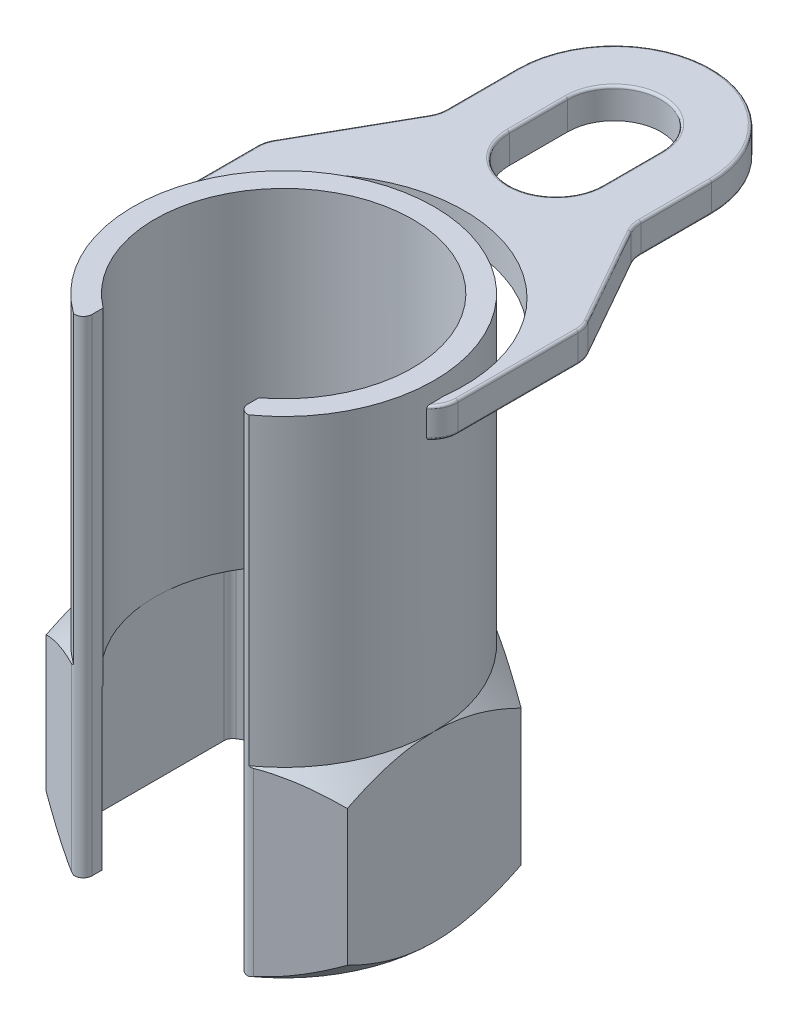
from build123d import *
from build123d.topology import SkipClean

# Parameters (mm, degrees)
EXTRUDE1_DEPTH     = 37.5
EXTRUDE2_DEPTH     = 62.5
SKETCH8_OUTSIDE_W  = 292.536
SKETCH8_OUTSIDE_H  = 292.878
SKETCH8_OUTSIDE_R  = 30.960408185
CUT_EXTRUDE4_DEPTH = 101
CUT_EXTRUDE4_DRAFT = -45
SKETCH19_OUTSIDE_W = 167.536
SKETCH19_OUTSIDE_H = 167.878
SKETCH19_OUTSIDE_R = 30.960308185
CUT_EXTRUDE6_DEPTH = 38.5
CUT_EXTRUDE6_DRAFT = -45
CUT_EXTRUDE9_START = -32.710308
CUT_EXTRUDE9_DEPTH = 32.710309
FILLET1_R          = 1.8
EXTRUDE7_DEPTH     = 6.2
CUT_EXTRUDE8_REACH = 98.2
FILLET4_R          = 0.5


with BuildPart() as part:
    # Sketch1 → Extrude1 (new body)
    with BuildSketch(Plane(origin=(0, 0, 0), x_dir=(1, 0, 0), z_dir=(0, 1, 0))):
        with BuildLine():
            Line((-16, -21.124630174), (-16, -26.512395693))
            Line((-16, -26.512395693), (-30.960408185, -17.875))
            Line((-30.960408185, -17.875), (-30.960408185, 17.875))
            Line((-30.960408185, 17.875), (0, 35.75))
            Line((0, 35.75), (30.960408185, 17.875))
            Line((30.960408185, 17.875), (30.960408185, -17.875))
            Line((30.960408185, -17.875), (16, -26.512395693))
            Line((16, -26.512395693), (16, -21.124630174))
            ThreePointArc((16, -21.124630174), (0, 26.5), (-16, -21.124630174))
        make_face()
    extrude(amount=EXTRUDE1_DEPTH)

    # Sketch3 → Extrude2 (add)
    with BuildSketch(Plane(origin=(0, 37.5, 0), x_dir=(-1, 0, 0), z_dir=(0, 1, 0))):
        with BuildLine():
            Line((-16, 26.505484016), (-16, 21.124630174))
            ThreePointArc((-16, 21.124630174), (0, -26.5), (16, 21.124630174))
            Line((16, 21.124630174), (16, 26.505484016))
            ThreePointArc((16, 26.505484016), (0, -30.960308185), (-16, 26.505484016))
        make_face()
    extrude(amount=EXTRUDE2_DEPTH)


with BuildPart() as cut_extrude4_tool:
    # Sketch8 outside → Cut-Extrude4 (with draft: the straight prism first)
    with BuildSketch(Plane.XZ):
        with Locations((0, -4.619)):
            Rectangle(SKETCH8_OUTSIDE_W, SKETCH8_OUTSIDE_H)
        Circle(SKETCH8_OUTSIDE_R, mode=Mode.SUBTRACT)
    extrude(amount=-CUT_EXTRUDE4_DEPTH)
    # Cut-Extrude4: the draft: its side faces are tilted about the plane it starts from
    cut_extrude4_sides = [cut_extrude4_tool.faces().sort_by_distance(p)[0] for p in [
        (0, 50.5, -151.058),
        (146.268, 50.5, -4.619),
        (0, 50.5, 141.82),
        (-146.268, 50.5, -4.619),
        (-30.960408185, 50.5, 0),
    ]]
    draft(cut_extrude4_sides, Plane.XZ, CUT_EXTRUDE4_DRAFT)


with BuildPart() as part_1:
    add(part.part)

    # Cut-Extrude4: cut by cut_extrude4_tool
    add(cut_extrude4_tool.part, mode=Mode.SUBTRACT)


with BuildPart() as cut_extrude6_tool:
    # Sketch19 outside → Cut-Extrude6 (with draft: the straight prism first)
    with BuildSketch(Plane(origin=(0, 37.5, 0), x_dir=(-1, 0, 0), z_dir=(0, 1, 0))):
        with Locations((0, -4.619)):
            Rectangle(SKETCH19_OUTSIDE_W, SKETCH19_OUTSIDE_H)
        Circle(SKETCH19_OUTSIDE_R, mode=Mode.SUBTRACT)
    extrude(amount=-CUT_EXTRUDE6_DEPTH)
    # Cut-Extrude6: the draft: its side faces are tilted about the plane it starts from
    cut_extrude6_sides = [cut_extrude6_tool.faces().sort_by_distance(p)[0] for p in [
        (0, 18.25, -88.558),
        (-83.768, 18.25, -4.619),
        (0, 18.25, 79.32),
        (83.768, 18.25, -4.619),
        (30.960308185, 18.25, 0),
    ]]
    draft(cut_extrude6_sides, Plane(origin=(0, 37.5, 0), x_dir=(-1, 0, 0), z_dir=(0, 1, 0)), CUT_EXTRUDE6_DRAFT)


with BuildPart() as part_2:
    add(part_1.part)

    # Cut-Extrude6: cut by cut_extrude6_tool
    add(cut_extrude6_tool.part, mode=Mode.SUBTRACT)

    # Sketch26 → Cut-Extrude9 (cut)
    with BuildSketch(Plane.XZ.offset(CUT_EXTRUDE9_START)):
        Polygon((-26.5, -15.299782134), (0, -30.599564267), (26.5, -15.299782134), (26.5, 15.299782134), (0, 30.599564267), (-26.5, 15.299782134), align=None)
    extrude(amount=CUT_EXTRUDE9_DEPTH, mode=Mode.SUBTRACT)

    # Fillet1
    fillet1_edges = [part_2.edges().sort_by_distance(p)[0] for p in [
        (-26.5, 16.355154, -15.299782134),
        (-26.5, 16.355154, 15.299782134),
        (26.5, 16.355154, 15.299782134),
        (26.5, 16.355154, -15.299782134),
        (-16, 18.74995, 26.512395693),
        (16, 18.74995, 26.512395693),
        (0, 16.355154, -30.599564267),
    ]]
    fillet(fillet1_edges, radius=FILLET1_R)

    # Sketch16 → Extrude7 (add)
    with BuildSketch(Plane(origin=(0, 90, 0), x_dir=(-1, 0, 0), z_dir=(0, 1, 0))):
        with BuildLine():
            Line((-20, -68), (-20, -53.47309707))
            ThreePointArc((-20, -53.47309707), (-20.184242868, -52.048465648), (-20.724848103, -50.717576433))
            Line((-20.724848103, -50.717576433), (-32.275151897, -30.282423567))
            ThreePointArc((-32.275151897, -30.282423567), (-32.815757132, -28.951534352), (-33, -27.52690293))
            Line((-33, -27.52690293), (-33, -2.852215123))
            ThreePointArc((-33, -2.852215123), (-32.454409953, -0.441211176), (-30.923949989, 1.5))
            ThreePointArc((-30.923949989, 1.5), (0, -30.960308185), (30.923949989, 1.5))
            ThreePointArc((30.923949989, 1.5), (32.454409953, -0.441211176), (33, -2.852215123))
            Line((33, -2.852215123), (33, -27.52690293))
            ThreePointArc((33, -27.52690293), (32.815757132, -28.951534352), (32.275151897, -30.282423567))
            Line((32.275151897, -30.282423567), (20.724848103, -50.717576433))
            ThreePointArc((20.724848103, -50.717576433), (20.184242868, -52.048465648), (20, -53.47309707))
            Line((20, -53.47309707), (20, -68))
            ThreePointArc((20, -68), (0, -88), (-20, -68))
        make_face()
    extrude(amount=EXTRUDE7_DEPTH)

    # Sketch25 → Cut-Extrude8 (cut, up to next)
    with BuildSketch(Plane.XZ.offset(-96.2), mode=Mode.PRIVATE) as cut_extrude8_sk1:
        with BuildLine():
            Line((-9.6, -68), (-9.6, -56))
            ThreePointArc((-9.6, -56), (0, -46.4), (9.6, -56))
            Line((9.6, -56), (9.6, -68))
            ThreePointArc((9.6, -68), (0, -77.6), (-9.6, -68))
        make_face()
    cut_extrude8_tool1 = extrude(cut_extrude8_sk1.sketch, amount=CUT_EXTRUDE8_REACH, mode=Mode.PRIVATE) & part_2.part
    add(cut_extrude8_tool1.solids().sort_by_distance((0, 96.2, -62))[0], mode=Mode.SUBTRACT)
    # Sketch25 → Cut-Extrude8 (cut, up to next)
    with BuildSketch(Plane.XZ.offset(-96.2), mode=Mode.PRIVATE) as cut_extrude8_sk2:
        with BuildLine():
            ThreePointArc((30.895641811, -2), (0, -30.960308185), (-30.895641811, -2))
            ThreePointArc((-30.895641811, -2), (0, -37.153501937), (30.895641811, -2))
        make_face()
    cut_extrude8_tool2 = extrude(cut_extrude8_sk2.sketch, amount=CUT_EXTRUDE8_REACH, mode=Mode.PRIVATE) & part_2.part
    add(cut_extrude8_tool2.solids().sort_by_distance((0, 96.2, -36.438105))[0], mode=Mode.SUBTRACT)

    # Fillet4
    fillet4_edges = [part_2.edges().sort_by_distance(p)[0] for p in [
        (-32.454409953, 90, -0.441211176),
        (32.454409953, 90, -0.441211176),
        (33, 90, -15.189559026),
        (32.815757132, 90, -28.951534352),
        (26.5, 90, -40.5),
        (20.184242868, 90, -52.048465648),
        (20, 90, -60.736548535),
        (0, 90, -88),
        (-20, 90, -60.736548535),
        (-20.184242868, 90, -52.048465648),
        (-26.5, 90, -40.5),
        (-32.815757132, 90, -28.951534352),
        (-33, 90, -15.189559026),
        (-32.454409953, 96.2, -0.441211176),
        (32.454409953, 96.2, -0.441211176),
        (33, 96.2, -15.189559026),
        (32.815757132, 96.2, -28.951534352),
        (26.5, 96.2, -40.5),
        (20.184242868, 96.2, -52.048465648),
        (20, 96.2, -60.736548535),
        (0, 96.2, -88),
        (-20, 96.2, -60.736548535),
        (-20.184242868, 96.2, -52.048465648),
        (-26.5, 96.2, -40.5),
        (-32.815757132, 96.2, -28.951534352),
        (-33, 96.2, -15.189559026),
        (0, 96.2, -77.6),
        (9.6, 96.2, -62),
        (0, 96.2, -46.4),
        (-9.6, 96.2, -62),
    ]]
    fillet(fillet4_edges, radius=FILLET4_R)


solid = part_2.part
